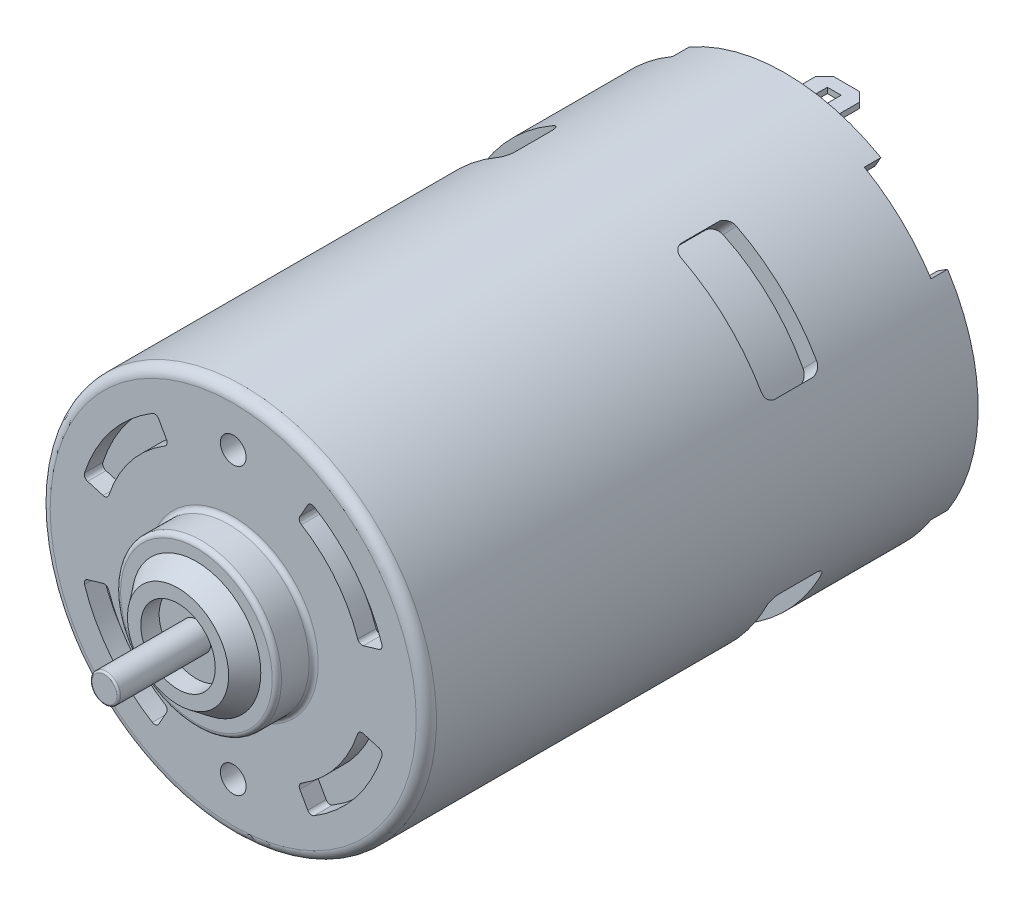
from build123d import *

# Parameters (mm, degrees)
CONG_1_R                            = 0.2
CONG_2_R                            = 0.5
CONG_3_R                            = 0.5
CONG_4_R                            = 0.5
CONG_5_R                            = 1.1
CONG_6_R                            = 0.5
ENL_V_MAT_EXTRU_1_DEPTH             = 1.8
CONG_7_R                            = 1.5
CONG_8_R                            = 1.5
ENL_V_MAT_EXTRU_3_DEPTH             = 4
CONG_9_R                            = 1
BOSS_EXTRU_1_DEPTH                  = 0.6
ESQUISSE5_W                         = 4.8
ESQUISSE5_H                         = 0.6
BOSS_EXTRU_2_DEPTH                  = 7
ENL_V_MAT_EXTRU_4_REACH             = 97.288
ESQUISSE6_W                         = 1.5
ESQUISSE6_H                         = 2.5
ESQUISSE7_W                         = 1.5
ESQUISSE7_H                         = 2.5
ENL_V_MAT_EXTRU_5_DEPTH             = 7
CHANFREIN1_SIZE                     = 1.3
CHANFREIN2_SIZE                     = 0.3
CHANFREIN3_SIZE                     = 0.3
CONG_10_R                           = 0.3
ENL_V_MAT_EXTRU_6_REACH             = 100.969
ENL_V_MAT_EXTRU_6_END_RADIUS        = 19
ESQUISSE8_W                         = 6
ESQUISSE8_H                         = 14
CONG_11_R                           = 1
R_P_TITION_CIRCULAIRE1_COUNT        = 4
CONG_11_OF_R_P_TITION_CIRCULAIRE1_R = 1
ESQUISSE9_R                         = 1.4
ENL_V_MAT_EXTRU_7_DEPTH             = 2
CONG_12_R                           = 0.5


with BuildPart() as part:
    # Esquisse1 → Révolution1 (revolve)
    with BuildSketch(Plane(origin=(0, 0, 0), x_dir=(0, 0, -1), z_dir=(1, 0, 0)), mode=Mode.PRIVATE) as r_volution1_sk:
        Polygon((0, 0), (0, 1.55), (10, 1.55), (10, 4.05), (8, 4.05), (8, 5.5), (10, 7), (10, 8.75), (14, 8.75), (14, 21), (74, 21), (74, 8.75), (78, 8.75), (78, 6.5), (80.018312738, 5.5), (80.018312738, 2.5), (85, 2.5), (85, 0), align=None)
    revolve(r_volution1_sk.sketch.rotate(Axis((0, 0, 0), (0, 0, -1)), 90), axis=Axis((0, 0, 0), (0, 0, -1)))

    # Congé1
    cong_1_edges = [part.edges().sort_by_distance(p)[0] for p in [
        (-1.55, 0, 0),
    ]]
    fillet(cong_1_edges, radius=CONG_1_R)

    # Congé2
    cong_2_edges = [part.edges().sort_by_distance(p)[0] for p in [
        (-8.75, 0, -10),
    ]]
    fillet(cong_2_edges, radius=CONG_2_R)

    # Congé3
    cong_3_edges = [part.edges().sort_by_distance(p)[0] for p in [
        (-8.75, 0, -78),
    ]]
    fillet(cong_3_edges, radius=CONG_3_R)

    # Congé4
    cong_4_edges = [part.edges().sort_by_distance(p)[0] for p in [
        (-8.75, 0, -74),
    ]]
    fillet(cong_4_edges, radius=CONG_4_R)

    # Congé5
    cong_5_edges = [part.edges().sort_by_distance(p)[0] for p in [
        (-21, 0, -14),
    ]]
    fillet(cong_5_edges, radius=CONG_5_R)

    # Congé6
    cong_6_edges = [part.edges().sort_by_distance(p)[0] for p in [
        (-8.75, 0, -14),
    ]]
    fillet(cong_6_edges, radius=CONG_6_R)

    # Esquisse2 → Enlèv. mat.-Extru.1 (cut)
    with BuildSketch(Plane(origin=(0, 0, -74), x_dir=(-1, 0, 0), z_dir=(0, 0, -1))):
        with BuildLine():
            Line((-7.5, 14.3), (7.5, 14.3))
            Line((7.5, 14.3), (7.5, 18.216476059))
            ThreePointArc((7.5, 18.216476059), (8.659571684, 17.694683333), (9.783065558, 17.099170398))
            Line((9.783065558, 17.099170398), (12, 20.974002838))
            Line((12, 20.974002838), (12, 21))
            Line((12, 21), (25.49648498, 16.353526664))
            Line((25.49648498, 16.353526664), (16.582174091, 10.63585927))
            ThreePointArc((16.582174091, 10.63585927), (19.699999298, -0.005257666), (16.576494592, -10.644708875))
            Line((16.576494592, -10.644708875), (23.558926509, -15.128525075))
            Line((23.558926509, -15.128525075), (12.316023481, -21.553041091))
            Line((12.316023481, -21.553041091), (9.773937086, -17.1043899))
            ThreePointArc((9.773937086, -17.1043899), (8.654848902, -17.696993826), (7.5, -18.216476059))
            Line((7.5, -18.216476059), (7.5, -14.3))
            Line((7.5, -14.3), (-7.5, -14.3))
            Line((-7.5, -14.3), (-7.5, -18.216476059))
            ThreePointArc((-7.5, -18.216476059), (-8.659571684, -17.694683333), (-9.783065558, -17.099170398))
            Line((-9.783065558, -17.099170398), (-13.485776152, -23.570892273))
            Line((-13.485776152, -23.570892273), (-22.57621331, -14.480455115))
            Line((-22.57621331, -14.480455115), (-16.582174091, -10.63585927))
            ThreePointArc((-16.582174091, -10.63585927), (-19.699999298, 0.005257666), (-16.576494592, 10.644708875))
            Line((-16.576494592, 10.644708875), (-23.240918336, 14.924313962))
            Line((-23.240918336, 14.924313962), (-12, 21))
            Line((-12, 21), (-9.773937086, 17.1043899))
            ThreePointArc((-9.773937086, 17.1043899), (-8.654848902, 17.696993826), (-7.5, 18.216476059))
            Line((-7.5, 18.216476059), (-7.5, 14.3))
        make_face()
        with BuildLine():
            Line((-8.5, -12.3), (8.5, -12.3))
            Line((8.5, -12.3), (8.5, -15.525462956))
            ThreePointArc((8.5, -15.525462956), (17.7, 0), (8.5, 15.525462956))
            Line((8.5, 15.525462956), (8.5, 12.3))
            Line((8.5, 12.3), (-8.5, 12.3))
            Line((-8.5, 12.3), (-8.5, 15.525462956))
            ThreePointArc((-8.5, 15.525462956), (-17.7, 0), (-8.5, -15.525462956))
            Line((-8.5, -15.525462956), (-8.5, -12.3))
        make_face(mode=Mode.SUBTRACT)
    extrude(amount=-ENL_V_MAT_EXTRU_1_DEPTH, mode=Mode.SUBTRACT)

    # Congé7
    cong_7_edges = [part.edges().sort_by_distance(p)[0] for p in [
        (-8.5, 15.525462956, -73.1),
        (-8.5, -15.525462956, -73.1),
        (8.5, -15.525462956, -73.1),
        (8.5, 15.525462956, -73.1),
    ]]
    fillet(cong_7_edges, radius=CONG_7_R)

    # Congé8
    cong_8_edges = [part.edges().sort_by_distance(p)[0] for p in [
        (8.5, 12.522597587, -74),
        (0, 12.3, -74),
        (-8.5, -12.522597587, -74),
        (0, -12.3, -74),
        (17.7, 0, -74),
        (8.5, -12.522597587, -74),
        (-17.7, 0, -74),
        (-8.5, 12.522597587, -74),
        (9.343832677, 14.094063011, -74),
        (-9.343832677, 14.094063011, -74),
        (-9.343832677, -14.094063011, -74),
        (9.343832677, -14.094063011, -74),
    ]]
    fillet(cong_8_edges, radius=CONG_8_R)

    # Esquisse3 → Enlèv. mat.-Extru.3 (cut)
    with BuildSketch(Plane(origin=(0, 0, -74), x_dir=(-1, 0, 0), z_dir=(0, 0, -1))):
        with BuildLine():
            ThreePointArc((-10.508924778, -3.25), (-9.79736855, -5.001156816), (-8.79651769, -6.60464053))
            Line((-8.79651769, -6.60464053), (-10.198039027, -11))
            ThreePointArc((-10.198039027, -11), (-13.011281019, -7.463683155), (-14.643684646, -3.25))
            Line((-14.643684646, -3.25), (-10.508924778, -3.25))
        make_face()
        with BuildLine():
            ThreePointArc((-8.796316847, 6.604908018), (-9.797292509, 5.001305779), (-10.508924778, 3.25))
            Line((-10.508924778, 3.25), (-14.643684646, 3.25))
            ThreePointArc((-14.643684646, 3.25), (-13.011281019, 7.463683155), (-10.198039027, 11))
            Line((-10.198039027, 11), (-8.796316847, 6.604908018))
        make_face()
        with BuildLine():
            Line((10.508924778, 3.25), (14.643684646, 3.25))
            ThreePointArc((14.643684646, 3.25), (13.011281019, 7.463683155), (10.198039027, 11))
            Line((10.198039027, 11), (8.796316847, 6.604908018))
            ThreePointArc((8.796316847, 6.604908018), (9.797292509, 5.001305779), (10.508924778, 3.25))
        make_face()
        with BuildLine():
            ThreePointArc((8.797598681, -6.603200546), (9.797777835, -5.000354938), (10.508924778, -3.25))
            Line((10.508924778, -3.25), (14.643684646, -3.25))
            ThreePointArc((14.643684646, -3.25), (13.011281019, -7.463683155), (10.198039027, -11))
            Line((10.198039027, -11), (8.797598681, -6.603200546))
        make_face()
    extrude(amount=-ENL_V_MAT_EXTRU_3_DEPTH, mode=Mode.SUBTRACT)

    # Congé9
    cong_9_edges = [part.edges().sort_by_distance(p)[0] for p in [
        (10.508924778, -3.25, -72),
        (8.79651769, -6.60464053, -72),
        (10.198039027, -11, -72),
        (14.643684646, -3.25, -72),
        (8.796316847, 6.604908018, -72),
        (10.508924778, 3.25, -72),
        (14.643684646, 3.25, -72),
        (10.198039027, 11, -72),
        (-14.643684646, 3.25, -72),
        (-10.508924778, 3.25, -72),
        (-8.796316847, 6.604908018, -72),
        (-10.198039027, 11, -72),
        (-8.797598681, -6.603200546, -72),
        (-10.508924778, -3.25, -72),
        (-14.643684646, -3.25, -72),
        (-10.198039027, -11, -72),
    ]]
    fillet(cong_9_edges, radius=CONG_9_R)

    # Esquisse4 → Boss.-Extru.1 (add)
    with BuildSketch(Plane(origin=(0, 0, -74), x_dir=(-1, 0, 0), z_dir=(0, 0, -1))):
        with BuildLine():
            Line((-7.5, 18.216476059), (-7.5, 14.3))
            Line((-7.5, 14.3), (7.5, 14.3))
            Line((7.5, 14.3), (7.5, 18.216476059))
            ThreePointArc((7.5, 18.216476059), (0, 19.7), (-7.5, 18.216476059))
        make_face()
        with BuildLine():
            Line((-6.5, 17.533967035), (-6.5, 15.3))
            Line((-6.5, 15.3), (6.5, 15.3))
            Line((6.5, 15.3), (6.5, 17.533967035))
            ThreePointArc((6.5, 17.533967035), (0, 18.7), (-6.5, 17.533967035))
        make_face(mode=Mode.SUBTRACT)
        with BuildLine():
            Line((7.5, -18.216476059), (7.5, -14.3))
            Line((7.5, -14.3), (-7.5, -14.3))
            Line((-7.5, -14.3), (-7.5, -18.216476059))
            ThreePointArc((-7.5, -18.216476059), (0, -19.7), (7.5, -18.216476059))
        make_face()
        with BuildLine():
            Line((6.5, -15.3), (-6.5, -15.3))
            Line((-6.5, -15.3), (-6.5, -17.533967035))
            ThreePointArc((-6.5, -17.533967035), (0, -18.7), (6.5, -17.533967035))
            Line((6.5, -17.533967035), (6.5, -15.3))
        make_face(mode=Mode.SUBTRACT)
    extrude(amount=BOSS_EXTRU_1_DEPTH)

    # Esquisse5 → Boss.-Extru.2 (add)
    with BuildSketch(Plane(origin=(0, 0, -74), x_dir=(-1, 0, 0), z_dir=(0, 0, -1))):
        with Locations((0, -16.3)):
            Rectangle(ESQUISSE5_W, ESQUISSE5_H)
        with Locations((0, 16.3)):
            Rectangle(ESQUISSE5_W, ESQUISSE5_H)
    extrude(amount=BOSS_EXTRU_2_DEPTH)

    # Esquisse6 → Enlèv. mat.-Extru.4 (cut, up to next)
    with BuildSketch(Plane.XZ.offset(16.6), mode=Mode.PRIVATE) as enl_v_mat_extru_4_sk1:
        with Locations((0, -78.1)):
            Rectangle(ESQUISSE6_W, ESQUISSE6_H)
    enl_v_mat_extru_4_tool1 = extrude(enl_v_mat_extru_4_sk1.sketch, amount=-ENL_V_MAT_EXTRU_4_REACH, mode=Mode.PRIVATE) & part.part
    add(enl_v_mat_extru_4_tool1.solids().sort_by_distance((0, -16.6, -78.1))[0], mode=Mode.SUBTRACT)

    # Esquisse7 → Enlèv. mat.-Extru.5 (cut)
    with BuildSketch(Plane(origin=(0, 16.6, 0), x_dir=(1, 0, 0), z_dir=(0, 1, 0))):
        with Locations((0, 78.1)):
            Rectangle(ESQUISSE7_W, ESQUISSE7_H)
    extrude(amount=-ENL_V_MAT_EXTRU_5_DEPTH, mode=Mode.SUBTRACT)

    # Chanfrein1
    chanfrein1_edges = [part.edges().sort_by_distance(p)[0] for p in [
        (-2.4, 16.3, -81),
        (2.4, 16.3, -81),
        (2.4, -16.3, -81),
        (-2.4, -16.3, -81),
    ]]
    chamfer(chanfrein1_edges, length=CHANFREIN1_SIZE)

    # Chanfrein2
    chanfrein2_edges = [part.edges().sort_by_distance(p)[0] for p in [
        (0, 16.6, -81),
    ]]
    chamfer(chanfrein2_edges, length=CHANFREIN2_SIZE)

    # Chanfrein3
    chanfrein3_edges = [part.edges().sort_by_distance(p)[0] for p in [
        (0, -16.6, -81),
    ]]
    chamfer(chanfrein3_edges, length=CHANFREIN3_SIZE)

    # Congé10
    cong_10_edges = [part.edges().sort_by_distance(p)[0] for p in [
        (-2.5, 0, -85),
    ]]
    fillet(cong_10_edges, radius=CONG_10_R)

    # Enlèv. mat.-Extru.6: up to this cylinder (the profile starts outside it)
    enl_v_mat_extru_6_end = Plane(origin=(0, 0, -56.2), z_dir=(0, 0, 1)) * Cylinder(ENL_V_MAT_EXTRU_6_END_RADIUS, 240.938, mode=Mode.PRIVATE)
    # Esquisse8 → Enlèv. mat.-Extru.6 (cut, up to the surface)
    with BuildSketch(Plane(origin=(14.400364869, 15.284943299, 0), x_dir=(0, 0, 1), z_dir=(0.6857316604236084, 0.7278544427924316, 0)), mode=Mode.PRIVATE) as enl_v_mat_extru_6_sk1:
        with Locations((-56.2, 0.080398654)):
            Rectangle(ESQUISSE8_W, ESQUISSE8_H)
    enl_v_mat_extru_6_tool1 = extrude(enl_v_mat_extru_6_sk1.sketch, amount=-ENL_V_MAT_EXTRU_6_REACH, mode=Mode.PRIVATE) - enl_v_mat_extru_6_end
    enl_v_mat_extru_6 = enl_v_mat_extru_6_tool1.solids().sort_by_distance((14.458883, 15.229811, -56.2))[0]
    add(enl_v_mat_extru_6, mode=Mode.SUBTRACT)

    # Congé11
    cong_11_edges = [part.edges().sort_by_distance(p)[0] for p in [
        (7.828687566, 18.400413895, -53.2),
        (17.977308646, 8.756290048, -53.2),
        (17.977308646, 8.756290048, -59.2),
        (7.828687566, 18.400413895, -59.2),
    ]]
    fillet(cong_11_edges, radius=CONG_11_R)

    # Répétition circulaire1: Enlèv. mat.-Extru.6 ×4 about axis
    r_p_tition_circulaire1_axis = Axis((0, 0, 0), (0, 0, 1))
    for i in range(1, R_P_TITION_CIRCULAIRE1_COUNT):
        add(enl_v_mat_extru_6.rotate(r_p_tition_circulaire1_axis, i * 360 / R_P_TITION_CIRCULAIRE1_COUNT), mode=Mode.SUBTRACT)

    # Congé11 of Répétition circulaire1
    cong_11_of_r_p_tition_circulaire1_edges = [part.edges().sort_by_distance(p)[0] for p in [
        (-18.400413895, 7.828687566, -53.2),
        (-8.756290048, 17.977308646, -53.2),
        (-8.756290048, 17.977308646, -59.2),
        (-18.400413895, 7.828687566, -59.2),
        (-7.828687566, -18.400413895, -53.2),
        (-17.977308646, -8.756290048, -53.2),
        (-17.977308646, -8.756290048, -59.2),
        (-7.828687566, -18.400413895, -59.2),
        (18.400413895, -7.828687566, -53.2),
        (8.756290048, -17.977308646, -53.2),
        (8.756290048, -17.977308646, -59.2),
        (18.400413895, -7.828687566, -59.2),
    ]]
    fillet(cong_11_of_r_p_tition_circulaire1_edges, radius=CONG_11_OF_R_P_TITION_CIRCULAIRE1_R)

    # Esquisse9 → Enlèv. mat.-Extru.7 (cut)
    with BuildSketch(Plane.XY.offset(-14)):
        with Locations((0, 15.5)):
            Circle(ESQUISSE9_R)
        with Locations((0, -15.5)):
            Circle(ESQUISSE9_R)
        with BuildLine():
            Line((8.350877193, -14.807526806), (7, -12.412191587))
            ThreePointArc((7, -12.412191587), (11.161390801, -8.859224311), (13.677079367, -4))
            Line((13.677079367, -4), (16.316515736, -4.771929825))
            ThreePointArc((16.316515736, -4.771929825), (13.315343411, -10.568899178), (8.350877193, -14.807526806))
        make_face()
        with BuildLine():
            Line((-7, -12.412191587), (-8.350877193, -14.807526806))
            ThreePointArc((-8.350877193, -14.807526806), (-13.315343411, -10.568899178), (-16.316515736, -4.771929825))
            Line((-16.316515736, -4.771929825), (-13.677079367, -4))
            ThreePointArc((-13.677079367, -4), (-11.161390801, -8.859224311), (-7, -12.412191587))
        make_face()
        with BuildLine():
            Line((8.350877193, 14.807526806), (7, 12.412191587))
            ThreePointArc((7, 12.412191587), (11.161390801, 8.859224311), (13.677079367, 4))
            Line((13.677079367, 4), (16.316515736, 4.771929825))
            ThreePointArc((16.316515736, 4.771929825), (13.315343411, 10.568899178), (8.350877193, 14.807526806))
        make_face()
        with BuildLine():
            Line((-13.677079367, 4), (-16.316515736, 4.771929825))
            ThreePointArc((-16.316515736, 4.771929825), (-13.315343411, 10.568899178), (-8.350877193, 14.807526806))
            Line((-8.350877193, 14.807526806), (-7, 12.412191587))
            ThreePointArc((-7, 12.412191587), (-11.161390801, 8.859224311), (-13.677079367, 4))
        make_face()
    extrude(amount=-ENL_V_MAT_EXTRU_7_DEPTH, mode=Mode.SUBTRACT)

    # Congé12
    cong_12_edges = [part.edges().sort_by_distance(p)[0] for p in [
        (13.677079367, 4, -15),
        (7, 12.412191587, -15),
        (8.350877193, 14.807526806, -15),
        (16.316515736, 4.771929825, -15),
        (7, -12.412191587, -15),
        (13.677079367, -4, -15),
        (16.316515736, -4.771929825, -15),
        (8.350877193, -14.807526806, -15),
        (-13.677079367, -4, -15),
        (-7, -12.412191587, -15),
        (-8.350877193, -14.807526806, -15),
        (-16.316515736, -4.771929825, -15),
        (-7, 12.412191587, -15),
        (-13.677079367, 4, -15),
        (-16.316515736, 4.771929825, -15),
        (-8.350877193, 14.807526806, -15),
    ]]
    fillet(cong_12_edges, radius=CONG_12_R)


solid = part.part
